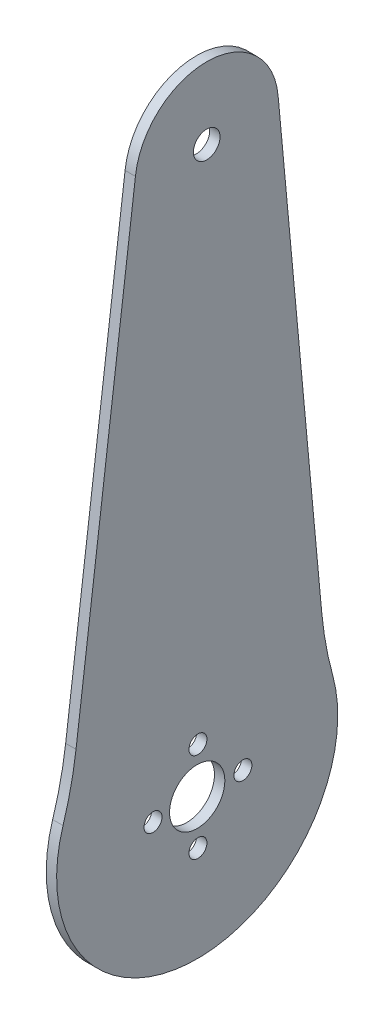
from build123d import *

# Parameters (mm, degrees)
SKETCH_2_R      = 1.3
SKETCH_2_R_2    = 4
SKETCH_2_R_3    = 1.925
EXTRUDE_1_DEPTH = 1.5


with BuildPart() as part:
    # 草圖2 → 填料-伸長1 (new body)
    with BuildSketch(Plane(origin=(0, 0, 0), x_dir=(0, 0, -1), z_dir=(1, 0, 0))):
        with BuildLine():
            Line((18.012072511, -21.441606673), (11.718522882, 46.276737912))
            ThreePointArc((11.718522882, 46.276737912), (1.55399875, 55.843411078), (-8.930005845, 46.627965677))
            Line((-8.930005845, 46.627965677), (-17.523002046, -20.837161438))
            ThreePointArc((-17.523002046, -20.837161438), (-18.27264724, -25.183298229), (-19.402359762, -29.446468708))
            ThreePointArc((-19.402359762, -29.446468708), (-19.752456192, -30.70663404), (-20.020797275, -31.986703271))
            ThreePointArc((-20.020797275, -31.986703271), (-0.345749536, -55.841970902), (20.12922907, -32.669648007))
            ThreePointArc((20.12922907, -32.669648007), (19.904578122, -31.38119307), (19.597542195, -30.109850035))
            ThreePointArc((19.597542195, -30.109850035), (18.61347279, -25.810724505), (18.012072511, -21.441606673))
        make_face()
        with Locations((-6.388480657, -35.515504866)):
            Circle(SKETCH_2_R, mode=Mode.SUBTRACT)
        with Locations((0.111519343, -42.015504866)):
            Circle(SKETCH_2_R, mode=Mode.SUBTRACT)
        with Locations((0, -35.515504866)):
            Circle(SKETCH_2_R_2, mode=Mode.SUBTRACT)
        with Locations((0.111519343, -29.015504866)):
            Circle(SKETCH_2_R, mode=Mode.SUBTRACT)
        with Locations((6.611519343, -35.515504866)):
            Circle(SKETCH_2_R, mode=Mode.SUBTRACT)
        with Locations((1.377596172, 45.472779649)):
            Circle(SKETCH_2_R_3, mode=Mode.SUBTRACT)
    extrude(amount=EXTRUDE_1_DEPTH)


solid = part.part
